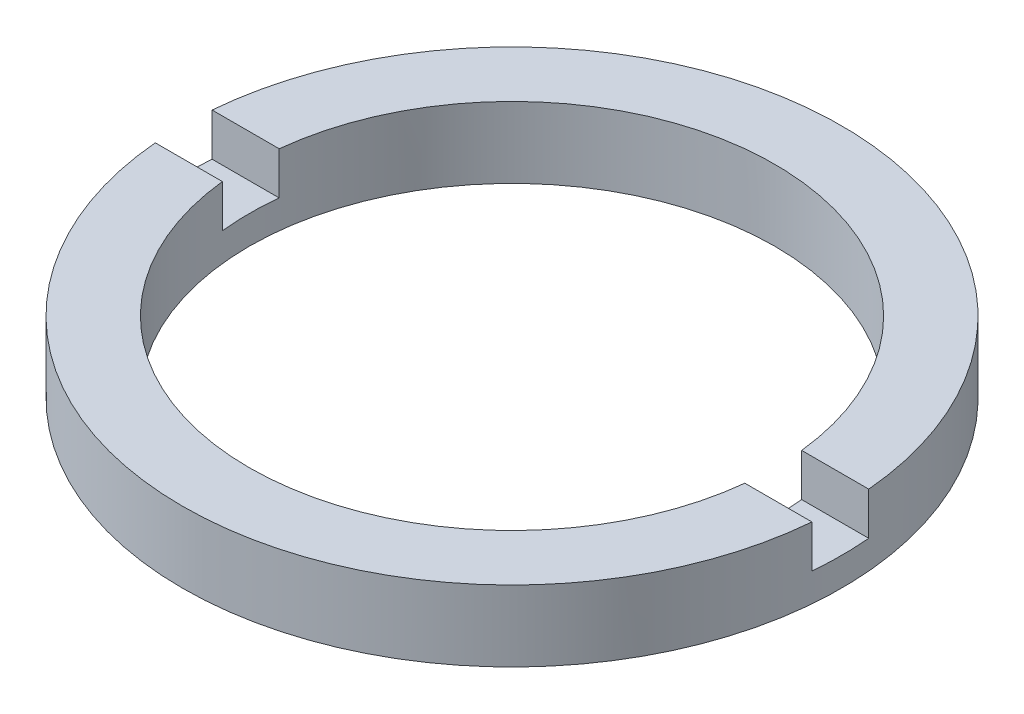
from build123d import *

# Parameters (mm, degrees)
SKETCH_1_W          = 2.35
SKETCH_1_H          = 2.5
SKETCH_2_W          = 53.705080546
SKETCH_2_H          = 2
CUT_EXTRUDE_1_DEPTH = 1.5


with BuildPart() as part:
    # 草图1 → 旋转1 (revolve)
    with BuildSketch(Plane.XY, mode=Mode.PRIVATE) as revolve_1_sk:
        with Locations((10.425, -3.214249787)):
            Rectangle(SKETCH_1_W, SKETCH_1_H)
    revolve(revolve_1_sk.sketch.rotate(Axis((0, 56.260842627, 0), (0, -1, 0)), 90), axis=Axis((0, 56.260842627, 0), (0, -1, 0)))  # turned: the seam where the file's is

    # 草图2 → 切除-拉伸1 (cut)
    with BuildSketch(Plane(origin=(0, -1.964249787, 0), x_dir=(1, 0, 0), z_dir=(0, 1, 0))):
        Rectangle(SKETCH_2_W, SKETCH_2_H)
    extrude(amount=-CUT_EXTRUDE_1_DEPTH, mode=Mode.SUBTRACT)


solid = part.part
